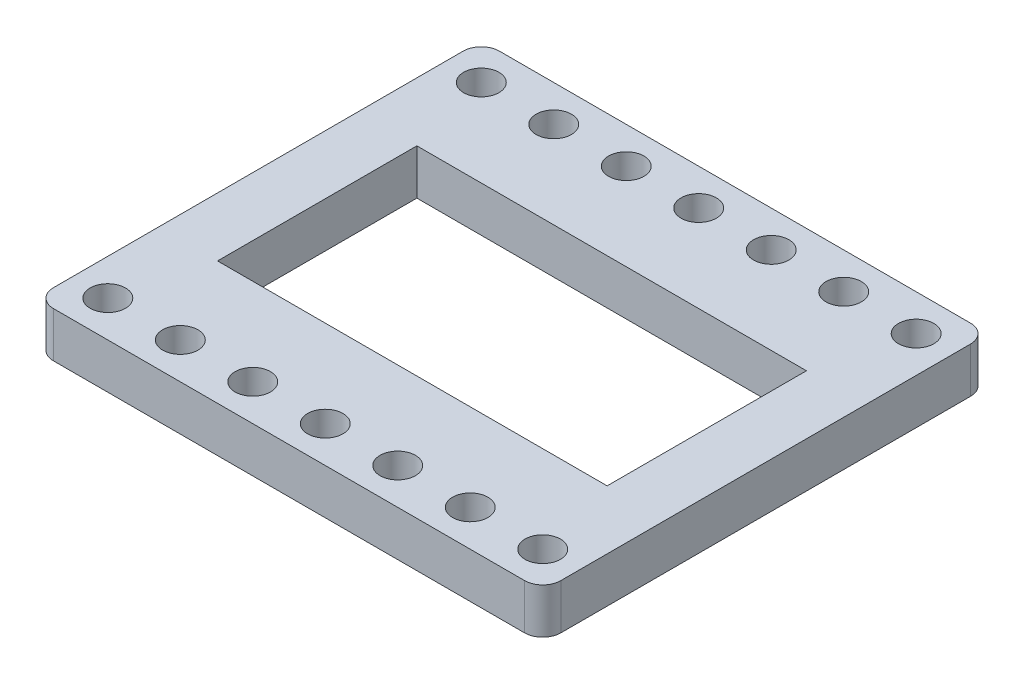
from build123d import *

# Parameters (mm, degrees)
BOSS_EXTRUDE1_DEPTH = 5
SKETCH2_R           = 1.95
SKETCH2_W           = 43
SKETCH2_H           = 22
CUT_EXTRUDE1_DEPTH  = 6


with BuildPart() as part:
    # Sketch1 → Boss-Extrude1 (new body)
    with BuildSketch(Plane(origin=(0, 0, 0), x_dir=(1, 0, 0), z_dir=(0, 1, 0))):
        with BuildLine():
            Line((-54, 0), (-2, 0))
            ThreePointArc((-2, 0), (-0.585786438, -0.585786438), (0, -2))
            Line((0, -2), (0, -47.22))
            ThreePointArc((0, -47.22), (-0.585786438, -48.634213562), (-2, -49.22))
            Line((-2, -49.22), (-54, -49.22))
            ThreePointArc((-54, -49.22), (-55.414213562, -48.634213562), (-56, -47.22))
            Line((-56, -47.22), (-56, -2))
            ThreePointArc((-56, -2), (-55.414213562, -0.585786438), (-54, 0))
        make_face()
    extrude(amount=BOSS_EXTRUDE1_DEPTH)

    # Sketch2 → Cut-Extrude1 (cut, through all)
    with BuildSketch(Plane(origin=(0, 5, 0), x_dir=(1, 0, 0), z_dir=(0, 1, 0))):
        with Locations((-4, -4)):
            Circle(SKETCH2_R)
        with Locations((-12, -4)):
            Circle(SKETCH2_R)
        with Locations((18, -4)):
            Circle(SKETCH2_R)
        with Locations((-68, -4)):
            Circle(SKETCH2_R)
        with Locations((-60, -4)):
            Circle(SKETCH2_R)
        with Locations((-52, -4)):
            Circle(SKETCH2_R)
        with Locations((-44, -4)):
            Circle(SKETCH2_R)
        with Locations((-36, -4)):
            Circle(SKETCH2_R)
        with Locations((-28, -4)):
            Circle(SKETCH2_R)
        with Locations((-20, -4)):
            Circle(SKETCH2_R)
        with Locations((-4, -45.22)):
            Circle(SKETCH2_R)
        with Locations((-12, -45.22)):
            Circle(SKETCH2_R)
        with Locations((18, -45.22)):
            Circle(SKETCH2_R)
        with Locations((-68, -45.22)):
            Circle(SKETCH2_R)
        with Locations((-60, -45.22)):
            Circle(SKETCH2_R)
        with Locations((-52, -45.22)):
            Circle(SKETCH2_R)
        with Locations((-44, -45.22)):
            Circle(SKETCH2_R)
        with Locations((-36, -45.22)):
            Circle(SKETCH2_R)
        with Locations((-28, -45.22)):
            Circle(SKETCH2_R)
        with Locations((-20, -45.22)):
            Circle(SKETCH2_R)
        with Locations((-28, -24.61)):
            Rectangle(SKETCH2_W, SKETCH2_H)
    extrude(amount=-CUT_EXTRUDE1_DEPTH, mode=Mode.SUBTRACT)


solid = part.part
